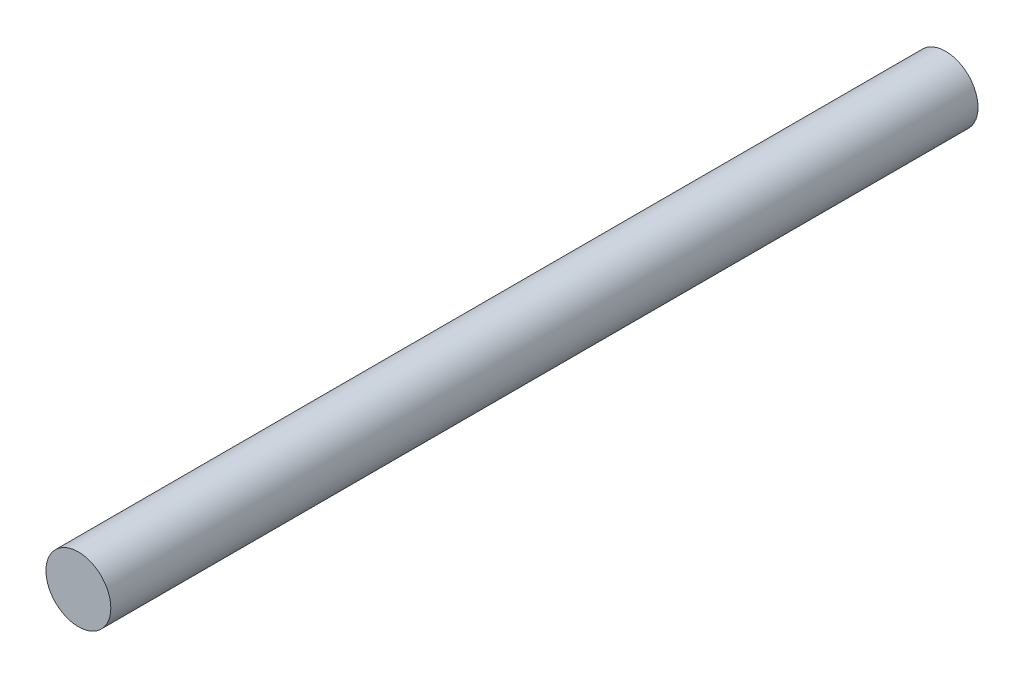
from build123d import *

# Parameters (mm, degrees)
SKETCH1_R      = 2.3749
EXTRUDE1_DEPTH = 63.5


with BuildPart() as part:
    # Sketch1 → Extrude1 (new body)
    with BuildSketch(Plane.XY):
        with Locations((-38.1, 0.127)):
            Circle(SKETCH1_R)
    extrude(amount=-EXTRUDE1_DEPTH)


solid = part.part
